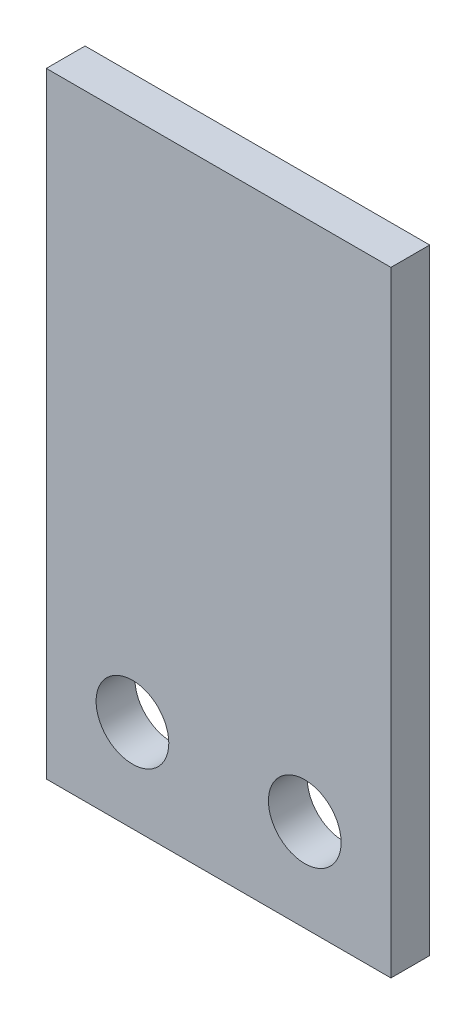
from build123d import *

# Parameters (mm, degrees)
SKETCH1_W           = 14.224
SKETCH1_H           = 25.4
SKETCH1_R           = 1.5
BOSS_EXTRUDE1_DEPTH = 1.6


with BuildPart() as part:
    # Sketch1 → Boss-Extrude1 (new body)
    with BuildSketch(Plane.XY):
        Rectangle(SKETCH1_W, SKETCH1_H)
        with Locations((-3.556, -8.89)):
            Circle(SKETCH1_R, mode=Mode.SUBTRACT)
        with Locations((3.556, -8.89)):
            Circle(SKETCH1_R, mode=Mode.SUBTRACT)
    extrude(amount=BOSS_EXTRUDE1_DEPTH)


solid = part.part
